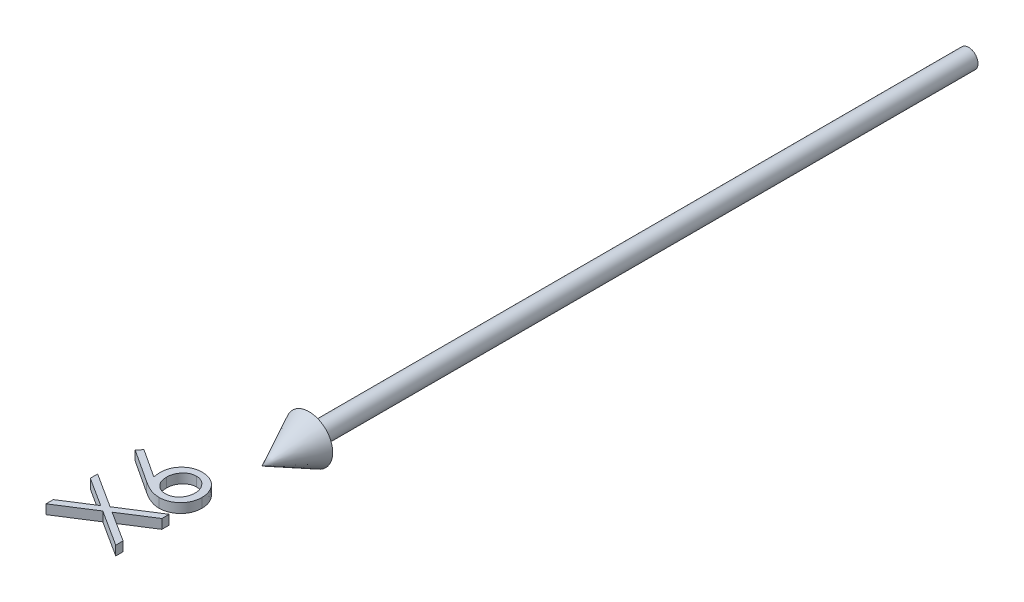
from build123d import *

# Parameters (mm, degrees)
BOSS_EXTRUDE1_DEPTH        = 1
BOSS_EXTRUDE1_DEPTH_BACK   = 1
BOSS_EXTRUDE1_2_DEPTH      = 1
BOSS_EXTRUDE1_2_DEPTH_BACK = 1


with BuildPart() as part:
    # Sketch2 → Revolve1 (revolve)
    with BuildSketch(Plane(origin=(0, 0, 0), x_dir=(1, 0, 0), z_dir=(0, 1, 0))):
        Polygon((0, -150), (5, -140), (2, -140), (2, 0), (0, 0), align=None)
    revolve(axis=Axis((0, 0, -41.949952025), (0, 0, 1)))


with BuildPart() as body_2:
    # Sketch3 → Boss-Extrude1 (new, two sides: drawn at the far end of the back side and taken through both)
    with BuildSketch(Plane(origin=(0, 0, 0), x_dir=(1, 0, 0), z_dir=(0, 1, 0)).offset(-BOSS_EXTRUDE1_DEPTH_BACK)):
        with BuildLine():
            Line((-15.384615385, -161.538461538), (-14.5703125, -160.501802885))
            Line((-14.5703125, -160.501802885), (-8.509615385, -164.465144231))
            add(Edge.make_bspline(
                [(-8.509615385, -164.465144231), (-8.551674787, -164.201271615), (-8.633716408, -163.686558243), (-8.64725046, -163.165561535), (-8.653846154, -162.911658654)],
                knots=[0, 0, 0, 0, 1.025318673, 2, 2, 2, 2], degree=3))
            add(Edge.make_bspline(
                [(-8.653846154, -162.911658654), (-8.649748532, -162.759205098), (-8.641682487, -162.45910481), (-8.579608839, -162.018504233), (-8.481786938, -161.595123063), (-8.339191529, -161.190716213), (-8.157038681, -160.803831781), (-7.93872886, -160.432250931), (-7.67299167, -160.082953357), (-7.376136314, -159.751460804), (-7.047369878, -159.450441004), (-6.698432357, -159.184140459), (-6.329351346, -158.959227404), (-5.940209844, -158.780037923), (-5.534053996, -158.636833796), (-5.109299766, -158.534889887), (-4.665230263, -158.473946284), (-4.363171943, -158.465718118), (-4.209735577, -158.461538462)],
                knots=[0, 0, 0, 0, 1.043709831, 2.054511743, 3.041122595, 4.01515914, 4.98481438, 5.965901842, 6.960491961, 7.985277438, 9.0096037, 10.00832444, 10.987059228, 11.962929573, 12.936966118, 13.931840027, 14.949438142, 16, 16, 16, 16], degree=3))
            add(Edge.make_bspline(
                [(-4.209735577, -158.461538462), (-3.999814704, -158.46762266), (-3.586740106, -158.479594923), (-2.985237872, -158.599394361), (-2.412540694, -158.784161413), (-1.878558323, -159.052483411), (-1.379592346, -159.379452551), (-0.938932231, -159.783085697), (-0.545933647, -160.243356809), (-0.217440639, -160.764070475), (0.050867747, -161.324382277), (0.243573381, -161.913037725), (0.362217491, -162.524295864), (0.377091411, -162.939172899), (0.384615385, -163.149038462)],
                knots=[0, 0, 0, 0, 1.031403119, 2.029557249, 3.004870281, 3.983165322, 4.960181699, 5.929903783, 6.912123683, 7.928973898, 8.949315281, 9.960468141, 10.968302741, 12, 12, 12, 12], degree=3))
            add(Edge.make_bspline(
                [(0.384615385, -163.149038462), (0.378084543, -163.35088996), (0.36514809, -163.750722436), (0.249307568, -164.33873873), (0.062885284, -164.904751258), (-0.199330062, -165.44149446), (-0.524946662, -165.939531208), (-0.91421359, -166.388660218), (-1.367671637, -166.776844482), (-1.87540114, -167.102802425), (-2.420231006, -167.362427857), (-2.98931297, -167.555305594), (-3.580257904, -167.66856415), (-3.980898774, -167.684354472), (-4.182692308, -167.692307692)],
                knots=[0, 0, 0, 0, 1.012172929, 2.004937354, 2.995255351, 3.995689452, 4.993936421, 5.973737378, 6.968231049, 7.979117505, 8.993136101, 9.989812463, 10.987515067, 12, 12, 12, 12], degree=3))
            add(Edge.make_bspline(
                [(-4.182692308, -167.692307692), (-4.337169093, -167.687244357), (-4.652581173, -167.676905992), (-5.13028415, -167.604720034), (-5.6190745, -167.488728056), (-6.03373533, -167.358827), (-6.373427567, -167.221574386), (-6.647299669, -167.107349216), (-6.92913284, -166.965174947), (-7.22859128, -166.813574742), (-7.53795742, -166.638902447), (-7.862401718, -166.448978235), (-8.196764265, -166.23855116), (-8.423667959, -166.091036177), (-8.539663462, -166.015625)],
                knots=[0, 0, 0, 0, 1.173818275, 2.396712641, 3.66331629, 4.989737886, 5.693666774, 6.447286557, 7.243889047, 8.091586357, 8.998013824, 9.943181721, 10.948533338, 12, 12, 12, 12], degree=3))
            Line((-8.539663462, -166.015625), (-15.384615385, -161.538461538))
        make_face()
        with BuildLine():
            add(Edge.make_bspline(
                [(-7.115384615, -163.194110577), (-7.112082335, -163.308388473), (-7.105632021, -163.531606401), (-7.067359224, -163.858911035), (-6.997698373, -164.169688556), (-6.901107529, -164.464029169), (-6.782022326, -164.743748653), (-6.629225554, -165.003303742), (-6.451252186, -165.248035491), (-6.248424191, -165.474033728), (-6.026504548, -165.678987203), (-5.788770456, -165.855474623), (-5.54099726, -166.007714295), (-5.281102705, -166.131493304), (-5.009189275, -166.2278794), (-4.726506739, -166.29760046), (-4.431159723, -166.336402255), (-4.230877567, -166.342857532), (-4.128605769, -166.346153846)],
                knots=[0, 0, 0, 0, 1.129656352, 2.206547016, 3.251334079, 4.271920891, 5.265058649, 6.249872215, 7.241923875, 8.251504132, 9.246416584, 10.222533834, 11.173322129, 12.116503788, 13.062124155, 14.020151864, 14.989013135, 16, 16, 16, 16], degree=3))
            add(Edge.make_bspline(
                [(-4.128605769, -166.346153846), (-4.027266421, -166.343374379), (-3.827564804, -166.337897099), (-3.534423223, -166.291263565), (-3.252971083, -166.216724728), (-2.984266134, -166.109048351), (-2.723149948, -165.978200106), (-2.47777361, -165.81024631), (-2.240188862, -165.61748415), (-2.021434681, -165.392416719), (-1.818352216, -165.14902973), (-1.640109433, -164.889544686), (-1.489386675, -164.617868563), (-1.364496219, -164.334783811), (-1.272559029, -164.036791143), (-1.202176111, -163.728729206), (-1.16369681, -163.406409539), (-1.157172802, -163.188193395), (-1.153846154, -163.076923077)],
                knots=[0, 0, 0, 0, 0.989367052, 1.949669134, 2.891858276, 3.827522767, 4.772653562, 5.738670152, 6.725809442, 7.756636004, 8.798867547, 9.819240912, 10.826537776, 11.829883227, 12.835515726, 13.868058748, 14.912904531, 16, 16, 16, 16], degree=3))
            add(Edge.make_bspline(
                [(-1.153846154, -163.076923077), (-1.157173061, -162.965652941), (-1.163697577, -162.747437155), (-1.202173196, -162.425114893), (-1.272569713, -162.117062539), (-1.364457508, -161.819035065), (-1.489531157, -161.5360794), (-1.639166208, -161.264640752), (-1.819445103, -161.00760987), (-2.021085993, -160.76406449), (-2.241438867, -160.539932405), (-2.475632853, -160.342636683), (-2.725113333, -160.179930127), (-2.983239431, -160.043893841), (-3.253131579, -159.937409713), (-3.534379419, -159.862503907), (-3.827576232, -159.815969582), (-4.027270268, -159.810478684), (-4.128605769, -159.807692308)],
                knots=[0, 0, 0, 0, 1.087281468, 2.132306021, 3.165025708, 4.170830268, 5.174347389, 6.181816599, 7.194310624, 8.23672049, 9.267723423, 10.261267456, 11.222032883, 12.171822355, 13.107646935, 14.049997283, 15.01046367, 16, 16, 16, 16], degree=3))
            add(Edge.make_bspline(
                [(-4.128605769, -159.807692308), (-4.231010988, -159.810050706), (-4.431999129, -159.814679475), (-4.726374626, -159.867033544), (-5.010625546, -159.939643703), (-5.282965192, -160.049285317), (-5.542319679, -160.191727449), (-5.78999599, -160.365228545), (-6.027905239, -160.565936502), (-6.248858458, -160.797795021), (-6.451032293, -161.05013644), (-6.628980787, -161.318654893), (-6.78087835, -161.598454103), (-6.900737553, -161.893475451), (-6.997297489, -162.19974945), (-7.067110856, -162.519390965), (-7.105532253, -162.852627334), (-7.112058665, -163.078832996), (-7.115384615, -163.194110577)],
                knots=[0, 0, 0, 0, 0.978259475, 1.920005202, 2.851759169, 3.7803069, 4.719124913, 5.675758531, 6.668034766, 7.691045932, 8.733780038, 9.756656648, 10.768121246, 11.773215211, 12.79725739, 13.836288844, 14.897342417, 16, 16, 16, 16], degree=3))
        make_face(mode=Mode.SUBTRACT)
    extrude(amount=BOSS_EXTRUDE1_DEPTH + BOSS_EXTRUDE1_DEPTH_BACK)


with BuildPart() as body_3:
    # Sketch3 → Boss-Extrude1 2 (new, two sides: drawn at the far end of the back side and taken through both)
    with BuildSketch(Plane(origin=(0, 0, 0), x_dir=(1, 0, 0), z_dir=(0, 1, 0)).offset(-BOSS_EXTRUDE1_2_DEPTH_BACK)):
        Polygon((-15, -180.865384615), (-15, -179.311899038), (-8.864182692, -175.384615385), (-15, -171.457331731), (-15, -169.903846154), (-7.650240385, -174.606370192), (0, -169.711538462), (0, -171.265024038), (-6.436298077, -175.384615385), (0, -179.504206731), (0, -181.057692308), (-7.650240385, -176.159855769), align=None)
    extrude(amount=BOSS_EXTRUDE1_2_DEPTH + BOSS_EXTRUDE1_2_DEPTH_BACK)


solid = Compound([part.part, body_2.part, body_3.part])
